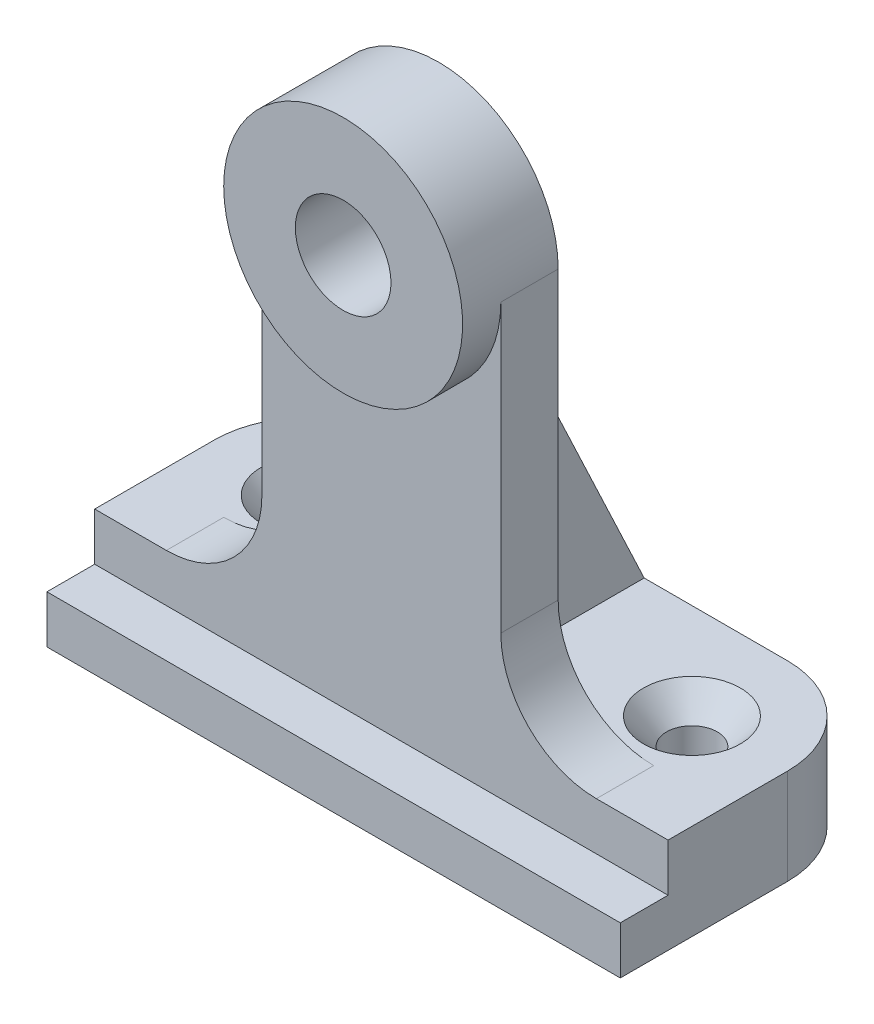
from build123d import *

# Parameters (mm, degrees)
BOSS_EXTRUDE4_DEPTH                              = 12.7
SKETCH10_W                                       = 76.2
SKETCH10_H                                       = 6.35
BOSS_EXTRUDE5_DEPTH                              = 6.35
CSK_FOR_1_4_FLAT_HEAD_MACHINE_SCREW1_D           = 6.7564
CSK_FOR_1_4_FLAT_HEAD_MACHINE_SCREW1_CSINK_D     = 12.8778
CSK_FOR_1_4_FLAT_HEAD_MACHINE_SCREW1_CSINK_ANGLE = 82
BOSS_EXTRUDE6_DEPTH                              = 7.62
FILLET1_R                                        = 12.7
SKETCH20_R                                       = 15.875
SKETCH20_R_2                                     = 6.35
BOSS_EXTRUDE7_DEPTH                              = 12.7
BOSS_EXTRUDE8_DEPTH                              = 6.35


with BuildPart() as part:
    # Sketch1 → Boss-Extrude4 (new body)
    with BuildSketch(Plane(origin=(0, 0, 0), x_dir=(1, 0, 0), z_dir=(0, 1, 0))):
        with BuildLine():
            Line((-25.4, 17.4625), (25.4, 17.4625))
            ThreePointArc((25.4, 17.4625), (34.380256121, 13.742756121), (38.1, 4.7625))
            Line((38.1, 4.7625), (38.1, -11.1125))
            Line((38.1, -11.1125), (-38.1, -11.1125))
            Line((-38.1, -11.1125), (-38.1, 4.7625))
            ThreePointArc((-38.1, 4.7625), (-34.380256121, 13.742756121), (-25.4, 17.4625))
        make_face()
    extrude(amount=BOSS_EXTRUDE4_DEPTH)

    # Sketch10 → Boss-Extrude5 (add)
    with BuildSketch(Plane(origin=(0, 0, 0), x_dir=(1, 0, 0), z_dir=(0, 1, 0))):
        with Locations((0, -14.2875)):
            Rectangle(SKETCH10_W, SKETCH10_H)
    extrude(amount=BOSS_EXTRUDE5_DEPTH)

    # CSK for 1/4 Flat Head Machine Screw1 (through all)
    with Locations(Plane(origin=(0, 12.7, 0), x_dir=(1, 0, 0), z_dir=(0, 1, 0))):
        with Locations((-25.4, 4.7625), (25.4, 4.7625)):
            CounterSinkHole(CSK_FOR_1_4_FLAT_HEAD_MACHINE_SCREW1_D / 2, CSK_FOR_1_4_FLAT_HEAD_MACHINE_SCREW1_CSINK_D / 2, counter_sink_angle=CSK_FOR_1_4_FLAT_HEAD_MACHINE_SCREW1_CSINK_ANGLE)

    # Sketch19 → Boss-Extrude6 (add)
    with BuildSketch(Plane.XY.offset(11.1125)):
        with BuildLine():
            Line((-15.875, 12.7), (15.875, 12.7))
            Line((15.875, 12.7), (15.875, 63.5))
            ThreePointArc((15.875, 63.5), (0, 47.625), (-15.875, 63.5))
            Line((-15.875, 63.5), (-15.875, 12.7))
        make_face()
    extrude(amount=-BOSS_EXTRUDE6_DEPTH)

    # Fillet1
    fillet1_edges = [part.edges().sort_by_distance(p)[0] for p in [
        (-15.875, 12.7, 7.3025),
        (15.875, 12.7, 7.3025),
    ]]
    fillet(fillet1_edges, radius=FILLET1_R)

    # Sketch20 → Boss-Extrude7 (add)
    with BuildSketch(Plane(origin=(0, 0, 3.4925), x_dir=(-1, 0, 0), z_dir=(0, 0, -1))):
        with Locations((0, 63.5)):
            Circle(SKETCH20_R)
        with Locations((0, 63.5)):
            Circle(SKETCH20_R_2, mode=Mode.SUBTRACT)
    extrude(amount=-BOSS_EXTRUDE7_DEPTH)

    # Sketch21 → Boss-Extrude8 (add, symmetric)
    with BuildSketch(Plane(origin=(0, 0, 0), x_dir=(0, 0, -1), z_dir=(1, 0, 0))):
        Polygon((-3.4925, 57.15), (17.4625, 12.7), (-3.4925, 12.7), align=None)
    extrude(amount=BOSS_EXTRUDE8_DEPTH, both=True)


solid = part.part
